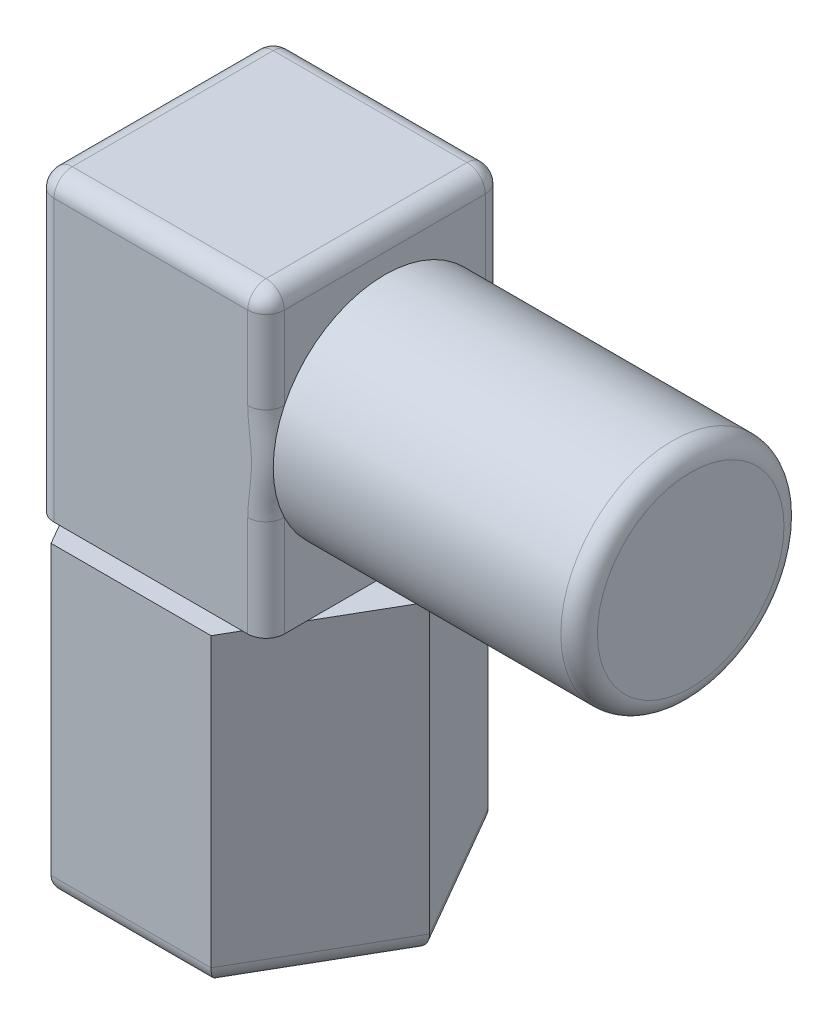
from build123d import *

# Parameters (mm, degrees)
BOSS_EXTRUDE1_DEPTH = 8.5
SKETCH2_W           = 6.4
SKETCH2_H           = 6.6
BOSS_EXTRUDE2_DEPTH = 8.3
SKETCH3_R           = 3.1
BOSS_EXTRUDE3_DEPTH = 8.5
SKETCH4_R           = 3.1
CUT_EXTRUDE1_DEPTH  = 8.5
FILLET1_R           = 0.508


with BuildPart() as part:
    # Sketch1 → Boss-Extrude1 (new body)
    with BuildSketch(Plane(origin=(0, 0, 0), x_dir=(1, 0, 0), z_dir=(0, 1, 0))):
        Polygon((4.445597073, 0), (2.222798536, 3.85), (-2.222798536, 3.85), (-4.445597073, 0), (-2.222798536, -3.85), (2.222798536, -3.85), align=None)
    extrude(amount=BOSS_EXTRUDE1_DEPTH)

    # Sketch2 → Boss-Extrude2 (add)
    with BuildSketch(Plane(origin=(0, 8.5, 0), x_dir=(1, 0, 0), z_dir=(0, 1, 0))):
        Rectangle(SKETCH2_W, SKETCH2_H)
    extrude(amount=BOSS_EXTRUDE2_DEPTH)

    # Sketch3 → Boss-Extrude3 (add)
    with BuildSketch(Plane(origin=(3.2, 0, 0), x_dir=(0, 0, -1), z_dir=(1, 0, 0))):
        with Locations((0, 12.65)):
            Circle(SKETCH3_R)
    extrude(amount=BOSS_EXTRUDE3_DEPTH)

    # Sketch4 → Cut-Extrude1 (cut)
    with BuildSketch(Plane.XZ):
        Circle(SKETCH4_R)
    extrude(amount=-CUT_EXTRUDE1_DEPTH, mode=Mode.SUBTRACT)

    # Fillet1
    fillet1_edges = [part.edges().sort_by_distance(p)[0] for p in [
        (-3.2, 12.65, -3.3),
        (-3.2, 12.65, 3.3),
        (3.2, 12.65, 3.3),
        (3.2, 12.65, -3.3),
        (-3.2, 16.8, 0),
        (0, 16.8, 3.3),
        (3.2, 16.8, 0),
        (0, 16.8, -3.3),
        (11.7, 12.65, 3.1),
        (0, 0, 3.85),
        (-3.334197805, 0, 1.925),
        (-3.334197805, 0, -1.925),
        (0, 0, -3.85),
        (3.334197805, 0, -1.925),
        (3.334197805, 0, 1.925),
    ]]
    fillet(fillet1_edges, radius=FILLET1_R)


solid = part.part
